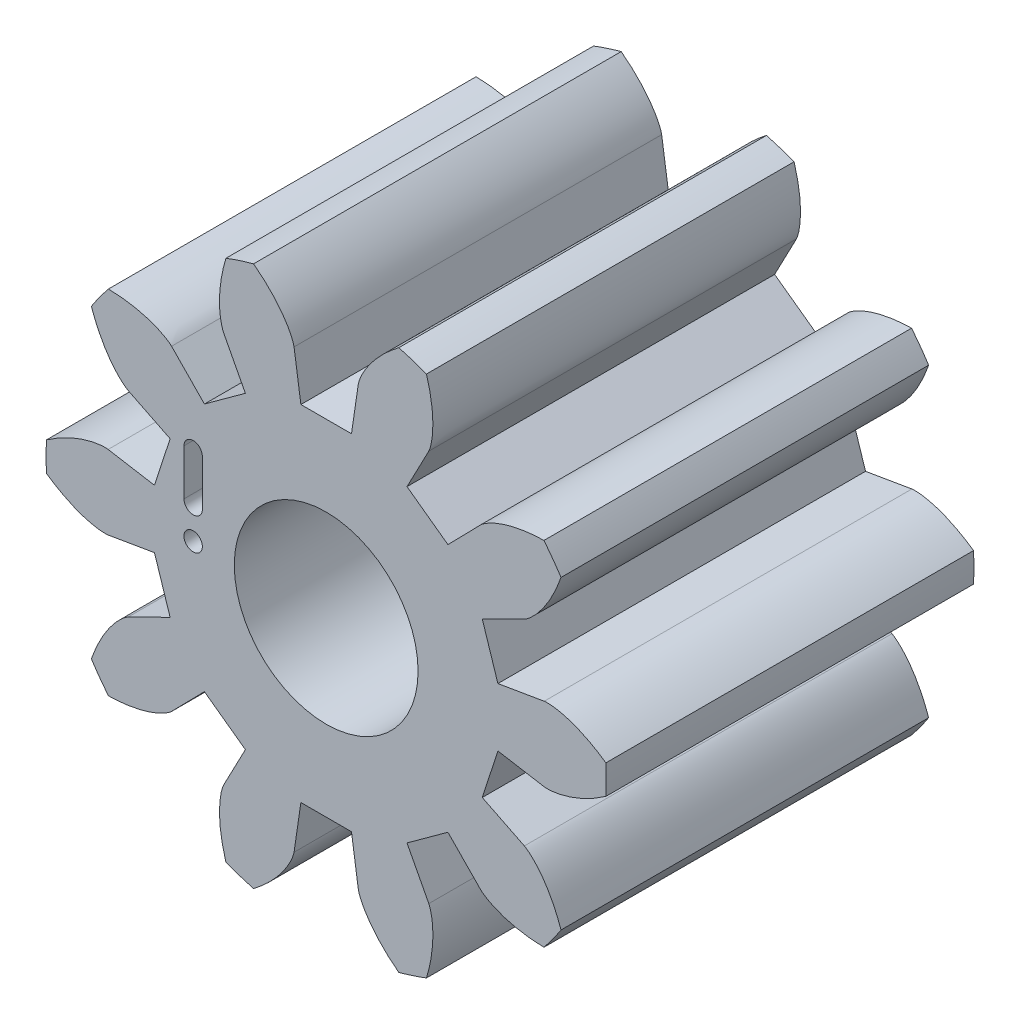
from build123d import *

# Parameters (mm, degrees)
SKETCH2_R               = 3.047560964
BOSS_EXTRUDE1_DEPTH     = 4
CUT_EXTRUDE2_DEPTH      = 5
CIRPATTERN1_COUNT       = 10
SKETCH3_R               = 1
CUT_EXTRUDE3_DEPTH      = 5.0000001
SKETCH4_R               = 0.1
LOCATIONCUT_DEPTH       = 5.0000001
LOCATIONCUT_DEPTH_BACK  = 1.0000001
CUT_EXTRUDE4_DEPTH      = 1.0000001
CUT_EXTRUDE4_DEPTH_BACK = 0.2


with BuildPart() as part:
    # Sketch2 → Boss-Extrude1 (new body)
    with BuildSketch(Plane.XY):
        Circle(SKETCH2_R)
    extrude(amount=BOSS_EXTRUDE1_DEPTH)

    # Sketch1 → Cut-Extrude2 (cut, through all)
    with BuildSketch(Plane.XY):
        with BuildLine():
            Line((2.156404657, 1.068318786), (1.698150443, 0.841292016))
            Line((1.698150443, 0.841292016), (1.868331607, 0.317528249))
            Line((1.868331607, 0.317528249), (2.372510042, 0.403214802))
            add(Edge.make_bspline(
                [(2.372510042, 0.403214802), (2.37611546, 0.403760673), (2.382985559, 0.404414485), (2.394235076, 0.405069977), (2.416506247, 0.405308323), (2.441728958, 0.404133992), (2.470204166, 0.401384399), (2.500745241, 0.397009563), (2.526796594, 0.392389707), (2.552706408, 0.386965815), (2.578433298, 0.380828943), (2.609476193, 0.372532832), (2.646517799, 0.361387983), (2.689490485, 0.34663299), (2.737801957, 0.327869155), (2.786502388, 0.306604412), (2.833955877, 0.283927929), (2.881286171, 0.259035925), (2.926639047, 0.233549078), (2.973023371, 0.205092488), (3.015477291, 0.177811446), (3.062154852, 0.145099187), (3.099572583, 0.118067878), (3.137430188, 0.088388544), (3.155735707, 0.073686183), (3.165039358, 0.066064728)],
                knots=[0, 0, 0, 0, 0, 0.015083688, 0.02853182, 0.046610139, 0.092110525, 0.119476176, 0.146842495, 0.174208854, 0.201574955, 0.228941013, 0.256307345, 0.307035032, 0.361767351, 0.41649966, 0.471231936, 0.525964282, 0.580696615, 0.635428982, 0.690161387, 0.744893688, 0.799626082, 0.854358408, 0.909090915, 0.909090915, 0.909090915, 0.909090915, 0.909090915], degree=4))
            ThreePointArc((3.165039358, 0.066064728), (3.010786981, 0.978263991), (2.599402501, 1.806915969))
            add(Edge.make_bspline(
                [(2.156404657, 1.068318786), (2.159642356, 1.069996379), (2.165584685, 1.073505577), (2.175071023, 1.079587573), (2.193228876, 1.092485413), (2.212944224, 1.108261004), (2.234364981, 1.127222779), (2.256501765, 1.148713689), (2.274862269, 1.167763832), (2.292635665, 1.18738126), (2.309841993, 1.20746798), (2.330079892, 1.23242623), (2.353496402, 1.263215112), (2.379589268, 1.300410864), (2.407644964, 1.343987896), (2.434545339, 1.38981683), (2.459607115, 1.43605495), (2.483266974, 1.484013053), (2.504977429, 1.531290097), (2.525776772, 1.581575984), (2.54408732, 1.628600599), (2.562622477, 1.682501754), (2.577005453, 1.726364133), (2.590187824, 1.77262736), (2.596355469, 1.795281535), (2.599402501, 1.806915969)],
                knots=[0, 0, 0, 0, 0, 0.015083688, 0.02853182, 0.046610139, 0.092110525, 0.119476176, 0.146842495, 0.174208854, 0.201574955, 0.228941013, 0.256307345, 0.307035032, 0.361767351, 0.41649966, 0.471231936, 0.525964282, 0.580696615, 0.635428982, 0.690161387, 0.744893688, 0.799626082, 0.854358408, 0.909090915, 0.909090915, 0.909090915, 0.909090915, 0.909090915], degree=4))
        make_face()
    cut_extrude2 = extrude(amount=CUT_EXTRUDE2_DEPTH, mode=Mode.SUBTRACT)

    # CirPattern1: Cut-Extrude2 ×10 about axis
    cirpattern1_axis = Axis((0, 0, 4.2), (0, 0, -1))
    for i in range(1, CIRPATTERN1_COUNT):
        add(cut_extrude2.rotate(cirpattern1_axis, i * 360 / CIRPATTERN1_COUNT), mode=Mode.SUBTRACT)

    # Sketch3 → Cut-Extrude3 (cut, through all)
    with BuildSketch(Plane.XY):
        Circle(SKETCH3_R)
    extrude(amount=CUT_EXTRUDE3_DEPTH, mode=Mode.SUBTRACT)

    # Sketch4 → LocationCut (cut, two sides)
    with BuildSketch(Plane.XY) as locationcut_sk:
        with Locations((-1.447560976, 0)):
            Circle(SKETCH4_R)
    extrude(amount=LOCATIONCUT_DEPTH, mode=Mode.SUBTRACT)
    extrude(locationcut_sk.sketch, amount=-LOCATIONCUT_DEPTH_BACK, mode=Mode.SUBTRACT)

    # Sketch7 → Cut-Extrude4 (cut, two sides)
    with BuildSketch(Plane.XY.offset(4)) as cut_extrude4_sk:
        with BuildLine():
            Line((-1.547560976, 0.85), (-1.547560976, 0.35))
            ThreePointArc((-1.547560976, 0.35), (-1.447560976, 0.25), (-1.347560976, 0.35))
            Line((-1.347560976, 0.35), (-1.347560976, 0.85))
            ThreePointArc((-1.347560976, 0.85), (-1.447560976, 0.95), (-1.547560976, 0.85))
        make_face()
    extrude(amount=CUT_EXTRUDE4_DEPTH, mode=Mode.SUBTRACT)
    extrude(cut_extrude4_sk.sketch, amount=-CUT_EXTRUDE4_DEPTH_BACK, mode=Mode.SUBTRACT)


solid = part.part
